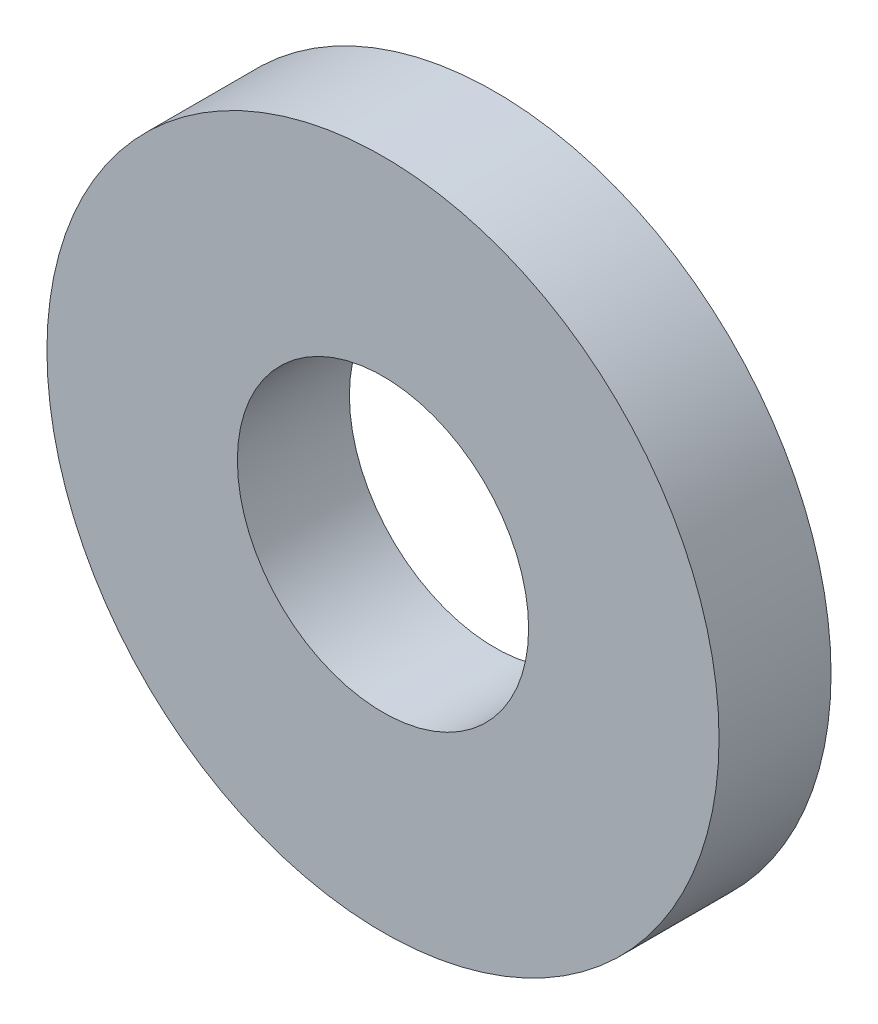
from build123d import *

# Parameters (mm, degrees)
SKETCH1_R           = 6
SKETCH1_R_2         = 2.6
BOSS_EXTRUDE1_DEPTH = 2


with BuildPart() as part:
    # Sketch1 → Boss-Extrude1 (new body)
    with BuildSketch(Plane.XY):
        Circle(SKETCH1_R)
        Circle(SKETCH1_R_2, mode=Mode.SUBTRACT)
    extrude(amount=BOSS_EXTRUDE1_DEPTH)


solid = part.part
